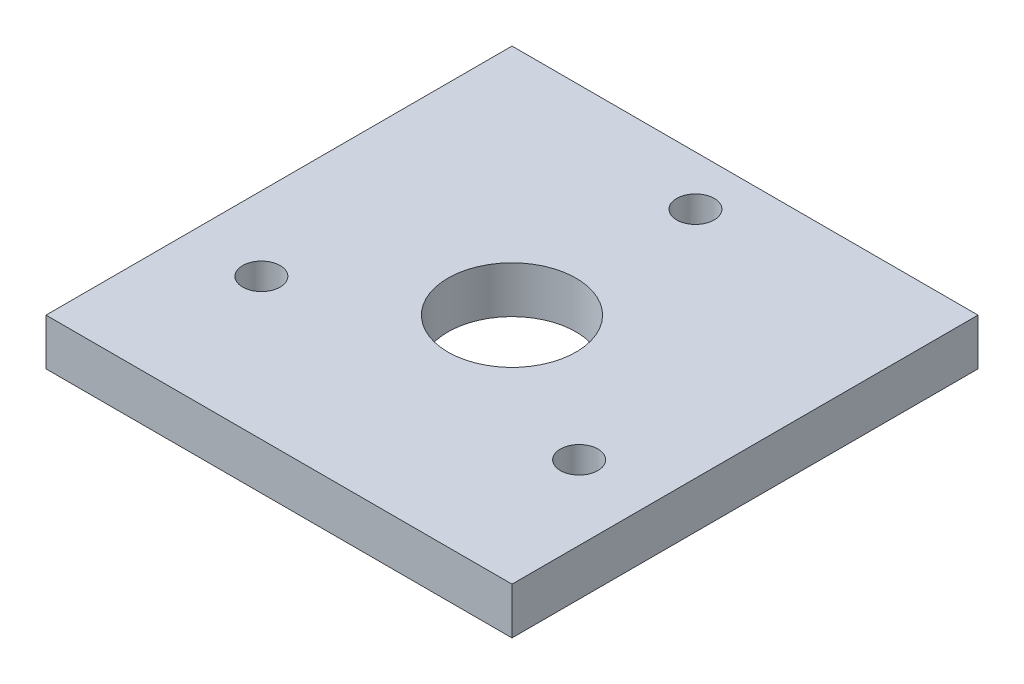
from build123d import *

# Parameters (mm, degrees)
SKETCH1_W           = 63.5
SKETCH1_H           = 63.5
SKETCH1_R           = 2.5527
SKETCH1_R_2         = 8.73125
BOSS_EXTRUDE1_DEPTH = 6.35


with BuildPart() as part:
    # Sketch1 → Boss-Extrude1 (new body)
    with BuildSketch(Plane(origin=(0, 0, 0), x_dir=(1, 0, 0), z_dir=(0, 1, 0))):
        Rectangle(SKETCH1_W, SKETCH1_H)
        with Locations((0, 25)):
            Circle(SKETCH1_R, mode=Mode.SUBTRACT)
        Circle(SKETCH1_R_2, mode=Mode.SUBTRACT)
        with Locations((21.650635095, -12.5)):
            Circle(SKETCH1_R, mode=Mode.SUBTRACT)
        with Locations((-21.650635095, -12.5)):
            Circle(SKETCH1_R, mode=Mode.SUBTRACT)
    extrude(amount=BOSS_EXTRUDE1_DEPTH)


solid = part.part
